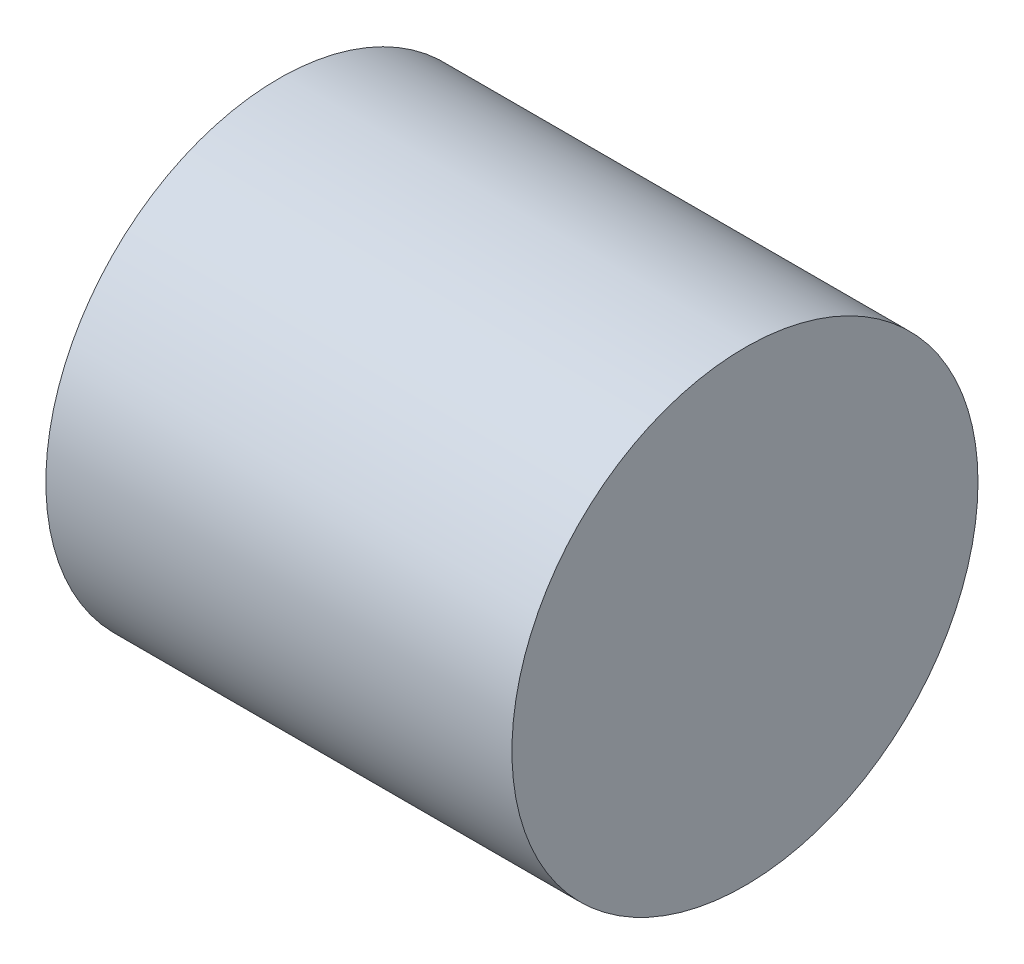
from build123d import *

# Parameters (mm, degrees)
SKETCH1_R           = 0.635
BOSS_EXTRUDE1_DEPTH = 1.27


with BuildPart() as part:
    # Sketch1 → Boss-Extrude1 (new body)
    with BuildSketch(Plane(origin=(0, 0, 0), x_dir=(0, 0, -1), z_dir=(1, 0, 0))):
        Circle(SKETCH1_R)
    extrude(amount=BOSS_EXTRUDE1_DEPTH)


solid = part.part
